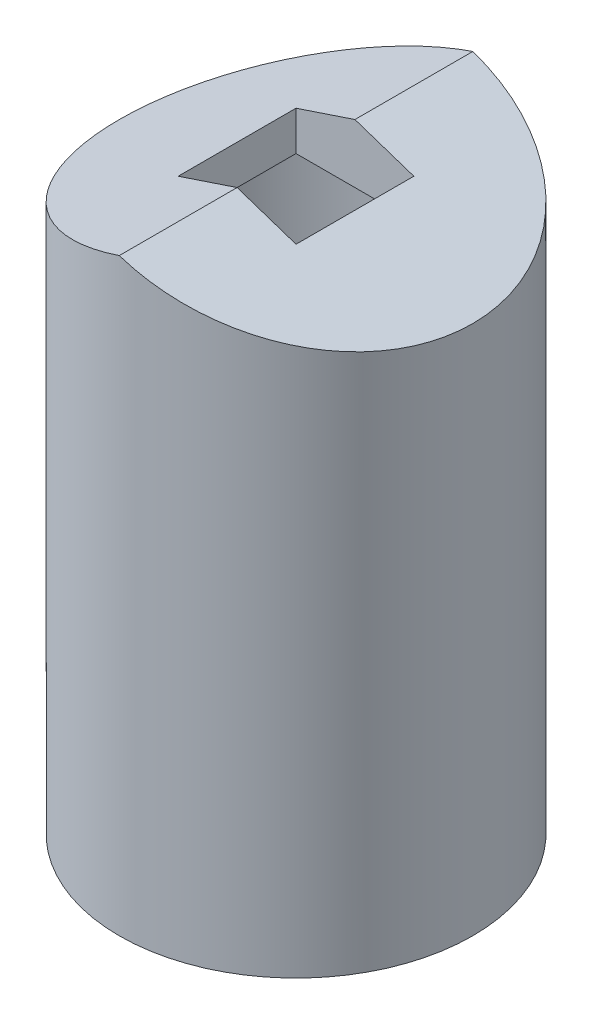
from build123d import *

# Parameters (mm, degrees)
BOSS_EXTRUDE3_DEPTH      = 9
BOSS_EXTRUDE3_DEPTH_BACK = 9
SKETCH7_R                = 14.642288151
SKETCH7_R_2              = 9
CUT_EXTRUDE3_DEPTH       = 32
SKETCH8_W                = 6
SKETCH8_H                = 6
CUT_EXTRUDE4_DEPTH       = 32
SKETCH9_R                = 8
CUT_EXTRUDE5_DEPTH       = 27


with BuildPart() as part:
    # Sketch1 → Revolve4 (revolve)
    with BuildSketch(Plane.XY):
        Polygon((0, 27), (9, 27), (9, 24.588457268), (9, 0), (0, 0), align=None)
    revolve(axis=Axis((0, 0, 0), (0, 1, 0)))

    # Sketch6 → Boss-Extrude3 (add, two sides)
    with BuildSketch(Plane.XY) as boss_extrude3_sk:
        Polygon((0, 27), (0, 30), (9, 27), align=None)
        Polygon((0, 30), (-9, 27), (0, 27), align=None)
    extrude(amount=BOSS_EXTRUDE3_DEPTH)
    extrude(boss_extrude3_sk.sketch, amount=-BOSS_EXTRUDE3_DEPTH_BACK)

    # Sketch7 → Cut-Extrude3 (cut)
    with BuildSketch(Plane.XZ):
        Circle(SKETCH7_R)
        Circle(SKETCH7_R_2, mode=Mode.SUBTRACT)
    extrude(amount=-CUT_EXTRUDE3_DEPTH, mode=Mode.SUBTRACT)

    # Sketch8 → Cut-Extrude4 (cut)
    with BuildSketch(Plane(origin=(0, 0, 0), x_dir=(-1, 0, 0), z_dir=(0, -1, 0))):
        Rectangle(SKETCH8_W, SKETCH8_H)
    extrude(amount=-CUT_EXTRUDE4_DEPTH, mode=Mode.SUBTRACT)

    # Sketch9 → Cut-Extrude5 (cut)
    with BuildSketch(Plane.XZ):
        Circle(SKETCH9_R)
    extrude(amount=-CUT_EXTRUDE5_DEPTH, mode=Mode.SUBTRACT)


solid = part.part
